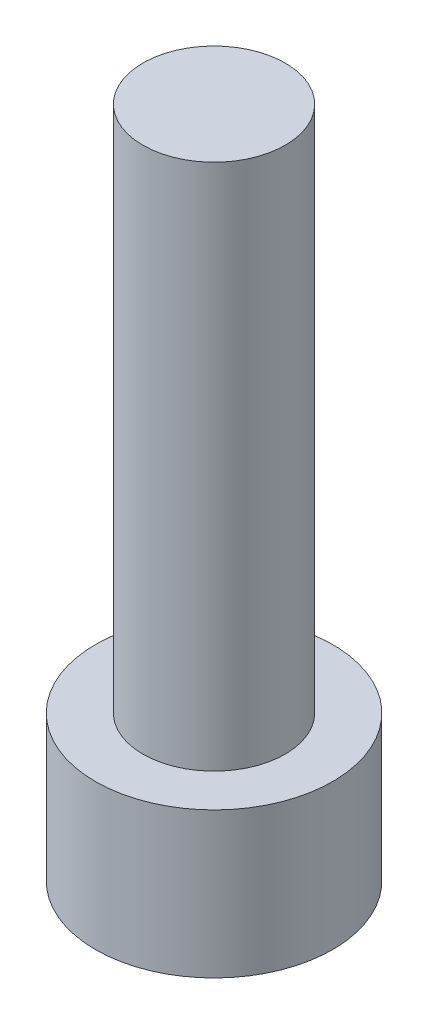
from build123d import *

# Parameters (mm, degrees)
SKETCH1_R           = 2.8575
BOSS_EXTRUDE1_DEPTH = 3.5052
CUT_EXTRUDE1_DEPTH  = 1.9558
SKETCH3_R           = 1.7145
BOSS_EXTRUDE2_DEPTH = 12.7


with BuildPart() as part:
    # Sketch1 → Boss-Extrude1 (new body)
    with BuildSketch(Plane(origin=(0, 0, 0), x_dir=(1, 0, 0), z_dir=(0, 1, 0))):
        Circle(SKETCH1_R)
    extrude(amount=BOSS_EXTRUDE1_DEPTH)

    # Sketch2 → Cut-Extrude1 (cut)
    with BuildSketch(Plane.XZ):
        Polygon((1.603951217, 0), (0.801975608, 1.3890625), (-0.801975608, 1.3890625), (-1.603951217, 0), (-0.801975608, -1.3890625), (0.801975608, -1.3890625), align=None)
    extrude(amount=-CUT_EXTRUDE1_DEPTH, mode=Mode.SUBTRACT)

    # Sketch3 → Boss-Extrude2 (add)
    with BuildSketch(Plane(origin=(0, 3.5052, 0), x_dir=(1, 0, 0), z_dir=(0, 1, 0))):
        Circle(SKETCH3_R)
    extrude(amount=BOSS_EXTRUDE2_DEPTH)


solid = part.part
